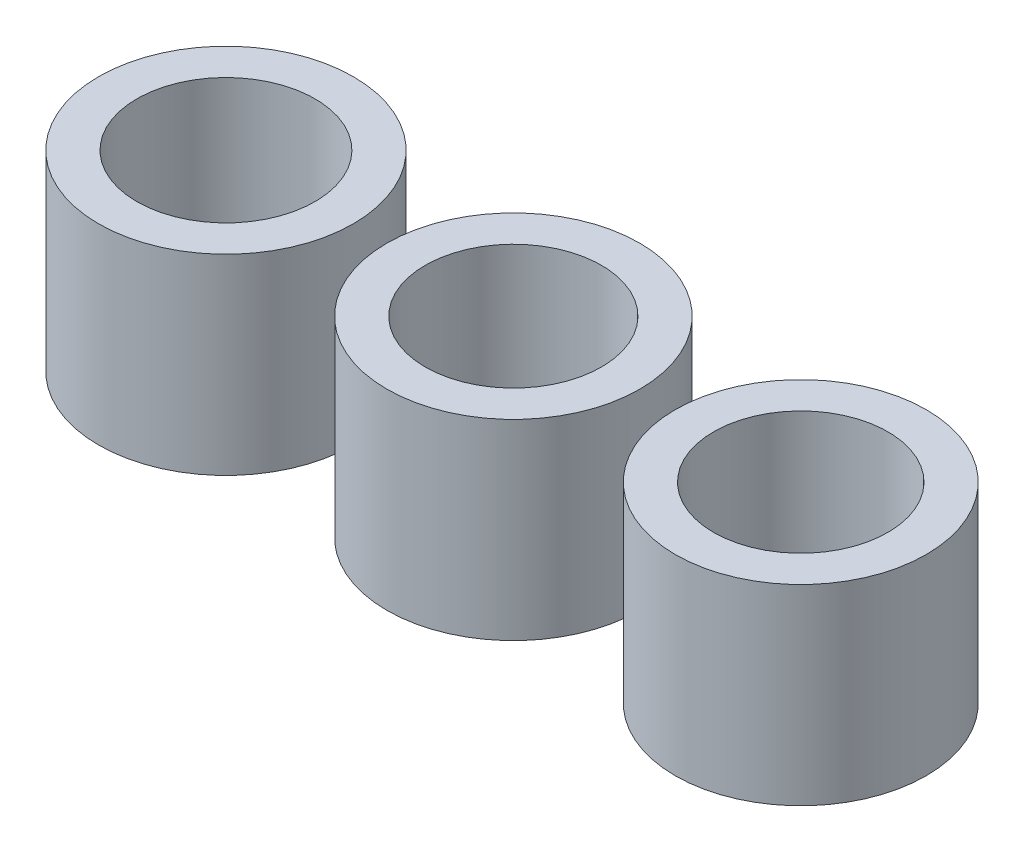
from build123d import *

# Parameters (mm, degrees)
SKETCH1_R             = 6.65
SKETCH1_R_2           = 4.65
BOSS_EXTRUDE1_DEPTH   = 10
SKETCH1_R_3           = 6.6
SKETCH1_R_4           = 4.6
BOSS_EXTRUDE1_2_DEPTH = 10
SKETCH1_R_5           = 6.55
SKETCH1_R_6           = 4.55
BOSS_EXTRUDE1_3_DEPTH = 10


with BuildPart() as part:
    # Sketch1 → Boss-Extrude1 (new body)
    with BuildSketch(Plane(origin=(0, 0, 0), x_dir=(1, 0, 0), z_dir=(0, 1, 0))):
        Circle(SKETCH1_R)
        Circle(SKETCH1_R_2, mode=Mode.SUBTRACT)
    extrude(amount=BOSS_EXTRUDE1_DEPTH)


with BuildPart() as body_2:
    # Sketch1 → Boss-Extrude1 2 (new body)
    with BuildSketch(Plane(origin=(0, 0, 0), x_dir=(1, 0, 0), z_dir=(0, 1, 0))):
        with Locations((15, 0)):
            Circle(SKETCH1_R_3)
        with Locations((15, 0)):
            Circle(SKETCH1_R_4, mode=Mode.SUBTRACT)
    extrude(amount=BOSS_EXTRUDE1_2_DEPTH)


with BuildPart() as body_3:
    # Sketch1 → Boss-Extrude1 3 (new body)
    with BuildSketch(Plane(origin=(0, 0, 0), x_dir=(1, 0, 0), z_dir=(0, 1, 0))):
        with Locations((30, 0)):
            Circle(SKETCH1_R_5)
        with Locations((30, 0)):
            Circle(SKETCH1_R_6, mode=Mode.SUBTRACT)
    extrude(amount=BOSS_EXTRUDE1_3_DEPTH)


solid = Compound([part.part, body_2.part, body_3.part])
